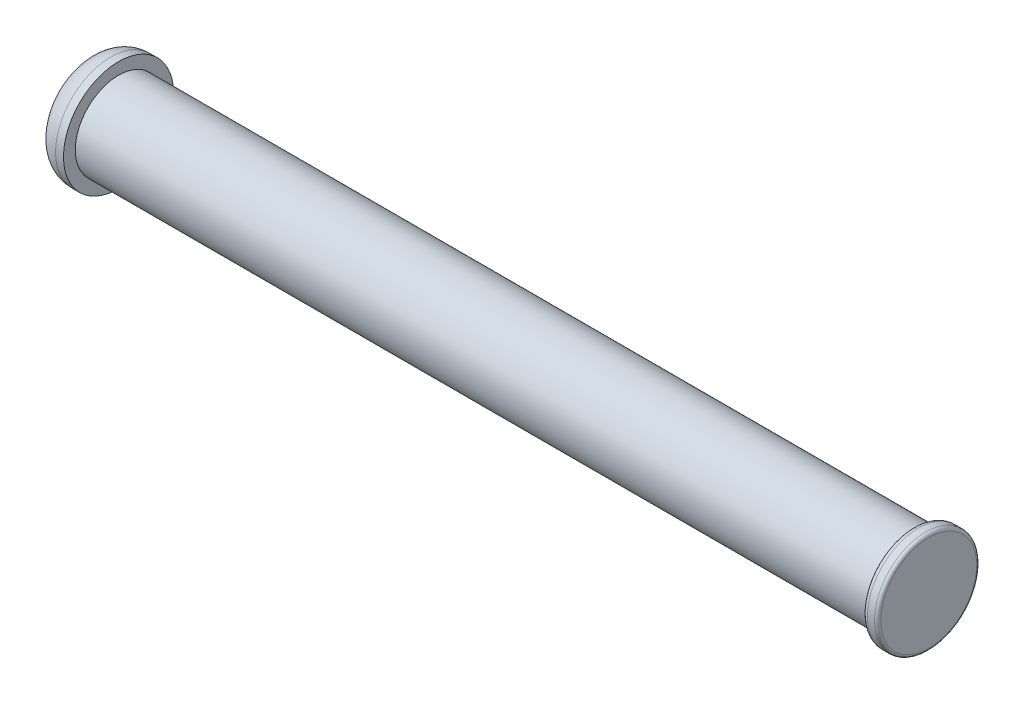
from build123d import *

# Parameters (mm, degrees)
SKETCH1_R           = 3.5
BOSS_EXTRUDE1_DEPTH = 2
SKETCH2_R           = 2.75
BOSS_EXTRUDE2_DEPTH = 50.5
SKETCH3_R           = 3.25
BOSS_EXTRUDE3_DEPTH = 1
FILLET1_R           = 1.5
FILLET2_R           = 0.35
FILLET3_R           = 0.2


with BuildPart() as part:
    # Sketch1 → Boss-Extrude1 (new body)
    with BuildSketch(Plane(origin=(0, 0, 0), x_dir=(0, 0, -1), z_dir=(1, 0, 0))):
        Circle(SKETCH1_R)
    extrude(amount=BOSS_EXTRUDE1_DEPTH)

    # Sketch2 → Boss-Extrude2 (add)
    with BuildSketch(Plane(origin=(2, 0, 0), x_dir=(0, 0, -1), z_dir=(1, 0, 0))):
        Circle(SKETCH2_R)
    extrude(amount=BOSS_EXTRUDE2_DEPTH)

    # Sketch3 → Boss-Extrude3 (add)
    with BuildSketch(Plane(origin=(52.5, 0, 0), x_dir=(0, 0, -1), z_dir=(1, 0, 0))):
        Circle(SKETCH3_R)
    extrude(amount=BOSS_EXTRUDE3_DEPTH)

    # Fillet1
    fillet1_edges = [part.edges().sort_by_distance(p)[0] for p in [
        (0, 0, 3.5),
    ]]
    fillet(fillet1_edges, radius=FILLET1_R)

    # Fillet2
    fillet2_edges = [part.edges().sort_by_distance(p)[0] for p in [
        (52.5, 0, 3.25),
    ]]
    fillet(fillet2_edges, radius=FILLET2_R)

    # Fillet3
    fillet3_edges = [part.edges().sort_by_distance(p)[0] for p in [
        (53.5, 0, 3.25),
    ]]
    fillet(fillet3_edges, radius=FILLET3_R)


solid = part.part
